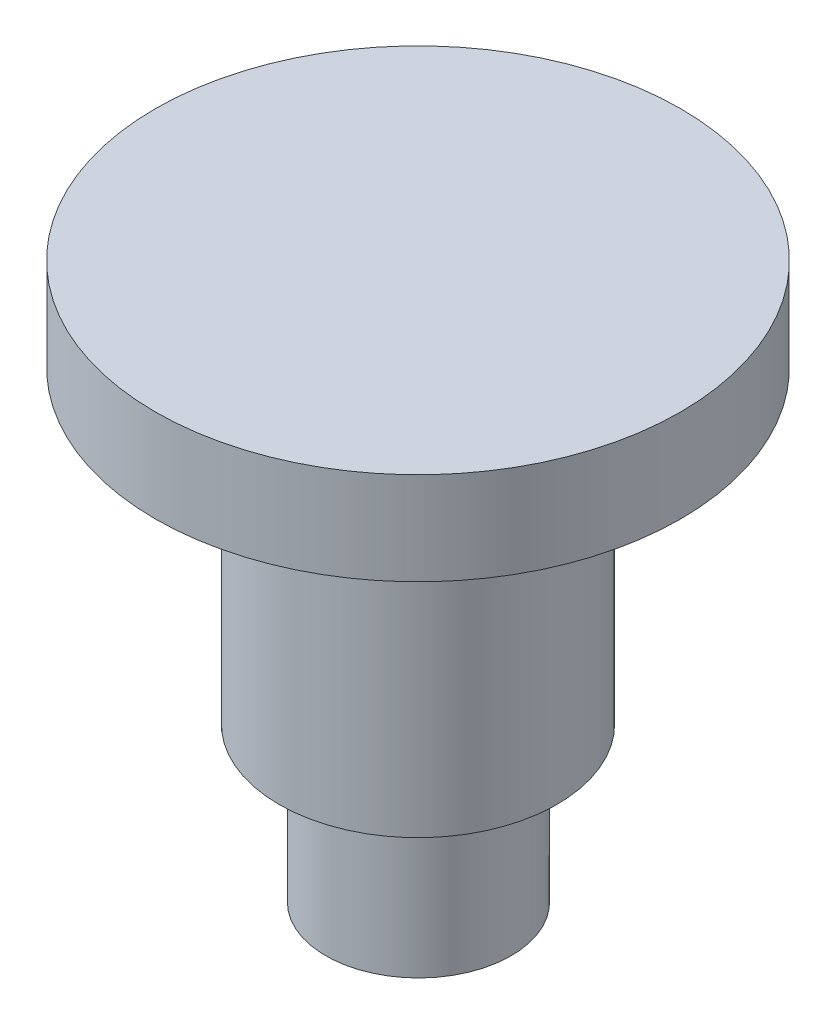
from build123d import *

# Parameters (mm, degrees)
SKETCH1_R           = 4.25
BOSS_EXTRUDE1_DEPTH = 1.5
SKETCH1_3_R         = 2.25
BOSS_EXTRUDE2_DEPTH = 5
SKETCH2_R           = 1.5
BOSS_EXTRUDE3_DEPTH = 2.5


with BuildPart() as part:
    # Sketch1 → Boss-Extrude1 (new body)
    with BuildSketch(Plane(origin=(0, 0, 0), x_dir=(1, 0, 0), z_dir=(0, 1, 0))):
        Circle(SKETCH1_R)
    extrude(amount=BOSS_EXTRUDE1_DEPTH)

    # Sketch1_3 → Boss-Extrude2 (add)
    with BuildSketch(Plane(origin=(0, 0, 0), x_dir=(1, 0, 0), z_dir=(0, 1, 0))):
        Circle(SKETCH1_3_R)
    extrude(amount=-BOSS_EXTRUDE2_DEPTH)

    # Sketch2 → Boss-Extrude3 (add)
    with BuildSketch(Plane.XZ.offset(5)):
        with Locations((0, -0.007534146)):
            Circle(SKETCH2_R)
    extrude(amount=BOSS_EXTRUDE3_DEPTH)


solid = part.part
